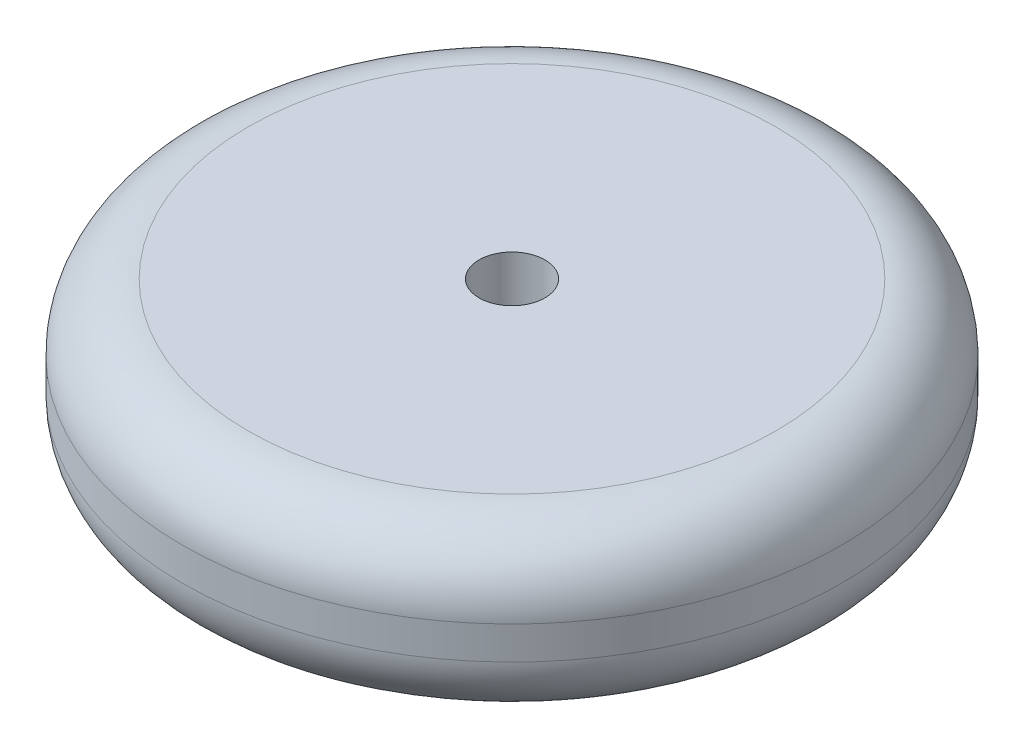
from build123d import *

# Parameters (mm, degrees)
SKETCH_1_R          = 40
EXTRUDE_1_DEPTH     = 10
FILLET_1_R          = 8
SKETCH_2_R          = 4
CUT_EXTRUDE_1_DEPTH = 10


with BuildPart() as part:
    # 草图1 → 凸台-拉伸1 (new body, symmetric)
    with BuildSketch(Plane(origin=(0, 0, 0), x_dir=(1, 0, 0), z_dir=(0, 1, 0))):
        Circle(SKETCH_1_R)
    extrude(amount=EXTRUDE_1_DEPTH, both=True)

    # 圆角1
    fillet_1_edges = [part.edges().sort_by_distance(p)[0] for p in [
        (-40, -10, 0),
        (-40, 10, 0),
    ]]
    fillet(fillet_1_edges, radius=FILLET_1_R)

    # 草图2 → 切除-拉伸1 (cut, symmetric)
    with BuildSketch(Plane(origin=(0, 0, 0), x_dir=(1, 0, 0), z_dir=(0, 1, 0))):
        Circle(SKETCH_2_R)
    extrude(amount=CUT_EXTRUDE_1_DEPTH, both=True, mode=Mode.SUBTRACT)


solid = part.part
